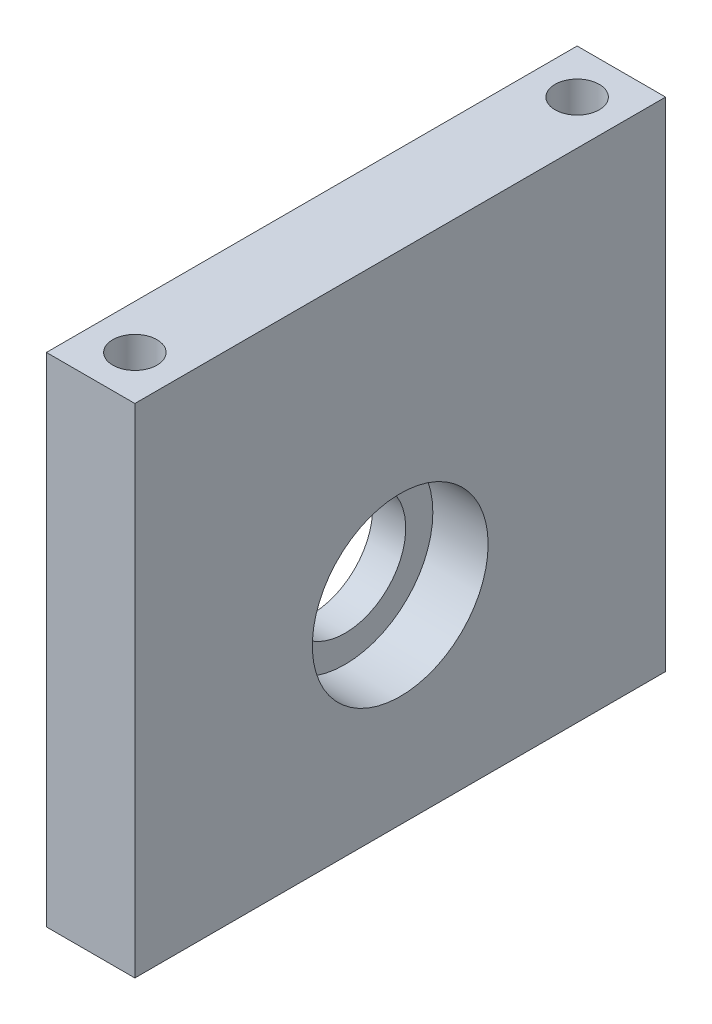
from build123d import *

# Parameters (mm, degrees)
ESQUISSE1_W             = 8
ESQUISSE1_H             = 48
BOSS_EXTRU_1_DEPTH      = 45
ESQUISSE28_R            = 7.95
ENL_V_MAT_EXTRU_1_DEPTH = 10
ESQUISSE29_R            = 8.1
ESQUISSE29_R_2          = 5.5
BOSS_EXTRU_2_DEPTH      = 3
ESQUISSE30_R            = 2
ENL_V_MAT_EXTRU_2_DEPTH = 15
ESQUISSE31_R            = 2
ENL_V_MAT_EXTRU_3_DEPTH = 15


with BuildPart() as part:
    # Esquisse1 → Boss.-Extru.1 (new body)
    with BuildSketch(Plane(origin=(0, 0, 0), x_dir=(1, 0, 0), z_dir=(0, 1, 0))):
        with Locations((4, 24)):
            Rectangle(ESQUISSE1_W, ESQUISSE1_H)
    extrude(amount=BOSS_EXTRU_1_DEPTH)

    # Esquisse28 → Enl_v. mat.-Extru.1 (cut)
    with BuildSketch(Plane(origin=(8, 0, 0), x_dir=(0, 0, -1), z_dir=(1, 0, 0))):
        with Locations((24, 18)):
            Circle(ESQUISSE28_R)
    extrude(amount=-ENL_V_MAT_EXTRU_1_DEPTH, mode=Mode.SUBTRACT)

    # Esquisse29 → Boss.-Extru.2 (add)
    with BuildSketch(Plane.ZY):
        with Locations((-24, 18)):
            Circle(ESQUISSE29_R)
        with Locations((-24, 18)):
            Circle(ESQUISSE29_R_2, mode=Mode.SUBTRACT)
    extrude(amount=-BOSS_EXTRU_2_DEPTH)

    # Esquisse30 → Enl_v. mat.-Extru.2 (cut)
    with BuildSketch(Plane.XZ):
        with Locations((4, -44)):
            Circle(ESQUISSE30_R)
        with Locations((4, -4)):
            Circle(ESQUISSE30_R)
    extrude(amount=-ENL_V_MAT_EXTRU_2_DEPTH, mode=Mode.SUBTRACT)

    # Esquisse31 → Enl_v. mat.-Extru.3 (cut)
    with BuildSketch(Plane(origin=(0, 45, 0), x_dir=(1, 0, 0), z_dir=(0, 1, 0))):
        with Locations((4, 44)):
            Circle(ESQUISSE31_R)
        with Locations((4, 4)):
            Circle(ESQUISSE31_R)
    extrude(amount=-ENL_V_MAT_EXTRU_3_DEPTH, mode=Mode.SUBTRACT)


solid = part.part
